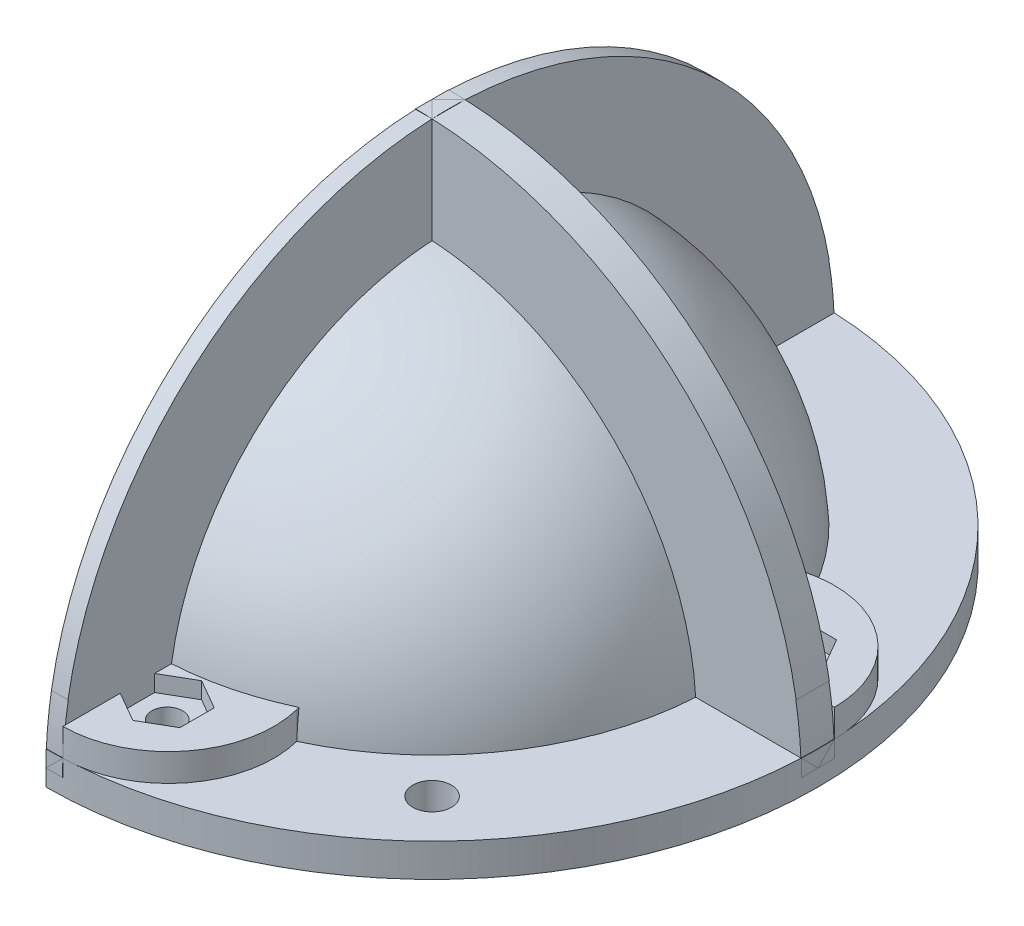
from build123d import *

# Parameters (mm, degrees)
BOSS_EXTRUDE1_DEPTH      = 1.5
BOSS_EXTRUDE1_DEPTH_BACK = 1.5
BOSS_EXTRUDE2_DEPTH      = 1.5
BOSS_EXTRUDE2_DEPTH_BACK = 1.5
SKETCH6_W                = 9.75
SKETCH6_H                = 3
SKETCH6_W_2              = 0.965
SKETCH6_H_2              = 1.5
BOSS_EXTRUDE4_DEPTH      = 2.5
CUT_EXTRUDE1_DEPTH       = 1.5
SKETCH11_R               = 1.4
CUT_EXTRUDE2_DEPTH       = 60.213596412
SKETCH13_R               = 10.5
BOSS_EXTRUDE5_DEPTH      = 2
BOSS_EXTRUDE5_DEPTH_BACK = 5
CUT_EXTRUDE3_DEPTH       = 10
CUT_EXTRUDE3_DEPTH_BACK  = 10
SKETCH15_R               = 9
CUT_EXTRUDE4_DEPTH       = 10
CUT_EXTRUDE5_DEPTH       = 4.1
SKETCH19_R               = 8.75
CUT_EXTRUDE6_DEPTH       = 2.5
SKETCH23_R               = 1.75
CUT_EXTRUDE9_DEPTH       = 10


with BuildPart() as part:
    # Sketch1 → Revolve1 (revolve)
    with BuildSketch(Plane.XY, mode=Mode.PRIVATE) as revolve1_sk:
        with BuildLine():
            Line((-20.885, 0), (-20.885, 11.793939121))
            ThreePointArc((-20.885, 11.793939121), (-12.091372858, 20.714220415), (0, 23.985))
            Line((0, 23.985), (0, 25.485))
            ThreePointArc((0, 25.485), (-18.020616319, 18.020616319), (-25.485, 0))
            Line((-25.485, 0), (-24.285, 0))
            Line((-24.285, 0), (-24.285, 0.5))
            Line((-24.285, 0.5), (-22.085, 0.5))
            Line((-22.085, 0.5), (-22.085, 0))
            Line((-22.085, 0), (-20.885, 0))
        make_face()
    revolve(revolve1_sk.sketch.rotate(Axis((0, 0, 0), (0, 1, 0)), 270), axis=Axis((0, 0, 0), (0, 1, 0)))



with BuildPart() as body_2:
    # Sketch2 → Boss-Extrude1 (new, two sides)
    with BuildSketch(Plane.XY) as boss_extrude1_sk:
        with BuildLine():
            Line((-24.9, 0), (-35, 0))
            ThreePointArc((-35, 0), (0, 35), (35, 0))
            Line((35, 0), (24.9, 0))
            ThreePointArc((24.9, 0), (0, 24.9), (-24.9, 0))
        make_face()
    extrude(amount=BOSS_EXTRUDE1_DEPTH)
    extrude(boss_extrude1_sk.sketch, amount=-BOSS_EXTRUDE1_DEPTH_BACK)

    # Sketch3 → Boss-Extrude2 (add, two sides)
    with BuildSketch(Plane(origin=(0, 0, 0), x_dir=(0, 0, -1), z_dir=(1, 0, 0))) as boss_extrude2_sk:
        with BuildLine():
            Line((35, 0), (24.9, 0))
            ThreePointArc((24.9, 0), (0, 24.9), (-24.9, 0))
            Line((-24.9, 0), (-35, 0))
            ThreePointArc((-35, 0), (0, 35), (35, 0))
        make_face()
    extrude(amount=BOSS_EXTRUDE2_DEPTH)
    extrude(boss_extrude2_sk.sketch, amount=-BOSS_EXTRUDE2_DEPTH_BACK)


with BuildPart() as part_1:
    add(part.part)

    add(body_2.part)  # Revolve3 merges body 2
    # Sketch6 → Revolve3 (revolve)
    with BuildSketch(Plane(origin=(0, 0, 0), x_dir=(0, 0, -1), z_dir=(1, 0, 0)), mode=Mode.PRIVATE) as revolve3_sk:
        with Locations((30.125, 0)):
            Rectangle(SKETCH6_W, SKETCH6_H)
        with Locations((24.7675, 0.75)):
            Rectangle(SKETCH6_W_2, SKETCH6_H_2)
    revolve(revolve3_sk.sketch.rotate(Axis((0, 0, 0), (0, -1, 0)), 180), axis=Axis((0, 0, 0), (0, -1, 0)))

    # Sketch9 → Cut-Revolve1 (revolve, cut)
    with BuildSketch(Plane.XY, mode=Mode.PRIVATE) as cut_revolve1_sk:
        with BuildLine():
            Line((34.507469645, 5.851028856), (35.470882951, 5.851028856))
            Line((35.470882951, 5.851028856), (35.470882951, 1.5))
            Line((35.470882951, 1.5), (34.96784237, 1.5))
            ThreePointArc((34.96784237, 1.5), (34.805712289, 3.682715312), (34.507469645, 5.851028856))
        make_face()
    revolve(cut_revolve1_sk.sketch.rotate(Axis((0, 0, 0), (0, 1, 0)), 180), axis=Axis((0, 0, 0), (0, 1, 0)), mode=Mode.SUBTRACT)

    # Sketch7 → Boss-Extrude4 (add)
    with BuildSketch(Plane(origin=(0, 1.5, 0), x_dir=(1, 0, 0), z_dir=(0, 1, 0))):
        with BuildLine():
            Line((23.044996888, 10.777909974), (22.609782845, 10.667601403))
            ThreePointArc((22.609782845, 10.667601403), (24.220082694, 6.195772291), (24.954959427, 1.5))
            Line((24.954959427, 1.5), (25.396559314, 1.5))
            Line((25.396559314, 1.5), (34.96784237, 1.5))
            ThreePointArc((34.96784237, 1.5), (31.274568745, 9.053705347), (23.044996888, 10.777909974))
        make_face()
        with BuildLine():
            ThreePointArc((10.667601403, -22.609782845), (6.195772291, -24.220082694), (1.5, -24.954959427))
            Line((1.5, -24.954959427), (1.5, -25.396559314))
            Line((1.5, -25.396559314), (1.5, -34.96784237))
            ThreePointArc((1.5, -34.96784237), (9.053705347, -31.274568745), (10.777909974, -23.044996888))
            Line((10.777909974, -23.044996888), (10.667601403, -22.609782845))
        make_face()
        with BuildLine():
            Line((-25.396559314, -1.5), (-34.96784237, -1.5))
            ThreePointArc((-34.96784237, -1.5), (-31.274568745, -9.053705347), (-23.044996888, -10.777909974))
            Line((-23.044996888, -10.777909974), (-22.609782845, -10.667601403))
            ThreePointArc((-22.609782845, -10.667601403), (-24.220082694, -6.195772291), (-24.954959427, -1.5))
            Line((-24.954959427, -1.5), (-25.396559314, -1.5))
        make_face()
        with BuildLine():
            ThreePointArc((-2.626689255, 34.901296588), (-9.387133949, 30.818973666), (-10.777909974, 23.044996888))
            ThreePointArc((-10.777909974, 23.044996888), (-6.25053836, 24.661021779), (-1.5, 25.396559314))
            Line((-1.5, 25.396559314), (-1.5, 34.96784237))
            ThreePointArc((-1.5, 34.96784237), (-2.063612885, 34.939111349), (-2.626689255, 34.901296588))
        make_face()
        with BuildLine():
            Line((-10.777909974, 23.044996888), (-10.667601403, 22.609782845))
            ThreePointArc((-10.667601403, 22.609782845), (-6.195772291, 24.220082694), (-1.5, 24.954959427))
            Line((-1.5, 24.954959427), (-1.5, 25.396559314))
            ThreePointArc((-1.5, 25.396559314), (-6.25053836, 24.661021779), (-10.777909974, 23.044996888))
        make_face()
    extrude(amount=BOSS_EXTRUDE4_DEPTH)

    # Sketch10 → Cut-Extrude1 (cut)
    with BuildSketch(Plane(origin=(0, 4, 0), x_dir=(1, 0, 0), z_dir=(0, 1, 0))):
        Polygon((4.2, -31.327119097), (6.9, -29.76827337), (6.9, -26.650581916), (4.2, -25.091736189), (1.5, -26.650581916), (1.5, -29.76827337), align=None)
        Polygon((-25.091736189, -4.2), (-26.650581916, -1.5), (-29.76827337, -1.5), (-31.327119097, -4.2), (-29.76827337, -6.9), (-26.650581916, -6.9), align=None)
        Polygon((-4.2, 31.327119097), (-6.9, 29.76827337), (-6.9, 26.650581916), (-4.2, 25.091736189), (-1.5, 26.650581916), (-1.5, 29.76827337), align=None)
        Polygon((31.327119097, 4.2), (29.76827337, 6.9), (26.650581916, 6.9), (25.091736189, 4.2), (26.650581916, 1.5), (29.76827337, 1.5), align=None)
    extrude(amount=-CUT_EXTRUDE1_DEPTH, mode=Mode.SUBTRACT)

    # Sketch11 → Cut-Extrude2 (cut, through all)
    with BuildSketch(Plane(origin=(0, 2.5, 0), x_dir=(1, 0, 0), z_dir=(0, 1, 0))):
        with Locations(Location((28.209427643, 4.2, 0), (0, 0, 270))):
            Circle(SKETCH11_R)
        with Locations(Location((4.2, -28.209427643, 0), (0, 0, 270))):
            Circle(SKETCH11_R)
        with Locations(Location((-28.209427643, -4.2, 0), (0, 0, 270))):
            Circle(SKETCH11_R)
        with Locations(Location((-4.2, 28.209427643, 0), (0, 0, 270))):
            Circle(SKETCH11_R)
    extrude(amount=-CUT_EXTRUDE2_DEPTH, mode=Mode.SUBTRACT)

    # Sketch13 → Boss-Extrude5 (add, two sides)
    with BuildSketch(Plane(origin=(-12.655947457, 12.655947457, 12.655947457), x_dir=(-0.8164965809277261, -0.408248290463863, -0.408248290463863), z_dir=(0.5773502691896257, -0.5773502691896258, -0.5773502691896258))) as boss_extrude5_sk:
        with Locations(Location((0, 0, 0), (0, 0, 270))):
            Circle(SKETCH13_R)
    extrude(amount=BOSS_EXTRUDE5_DEPTH)
    extrude(boss_extrude5_sk.sketch, amount=-BOSS_EXTRUDE5_DEPTH_BACK)

    # Sketch12 → Cut-Extrude3 (cut, two sides)
    with BuildSketch(Plane(origin=(-12.655947457, 12.655947457, 12.655947457), x_dir=(-0.8164965809277261, -0.408248290463863, -0.408248290463863), z_dir=(0.5773502691896257, -0.5773502691896258, -0.5773502691896258))) as cut_extrude3_sk:
        with BuildLine():
            Line((0.352106197, -6.089829327), (5.097893803, -3.349847575))
            ThreePointArc((5.097893803, -3.349847575), (5.282754963, 3.05), (-0.352106197, 6.089829327))
            Line((-0.352106197, 6.089829327), (-5.097893803, 3.349847575))
            ThreePointArc((-5.097893803, 3.349847575), (-5.282754963, -3.05), (0.352106197, -6.089829327))
        make_face()
    extrude(amount=CUT_EXTRUDE3_DEPTH, mode=Mode.SUBTRACT)
    extrude(cut_extrude3_sk.sketch, amount=-CUT_EXTRUDE3_DEPTH_BACK, mode=Mode.SUBTRACT)

    # Sketch15 → Cut-Extrude4 (cut)
    with BuildSketch(Plane(origin=(-11.501246918, 11.501246918, 11.501246918), x_dir=(-0.40824829046386274, 0.40824829046386296, -0.8164965809277264), z_dir=(0.5773502691896258, -0.5773502691896262, -0.5773502691896255))):
        Circle(SKETCH15_R)
    extrude(amount=CUT_EXTRUDE4_DEPTH, mode=Mode.SUBTRACT)

    # Sketch18 → Cut-Extrude5 (cut)
    with BuildSketch(Plane(origin=(-15.542698803, 15.542698803, 15.542698803), x_dir=(0.40824829046386274, -0.40824829046386296, 0.8164965809277264), z_dir=(-0.5773502691896258, 0.5773502691896262, 0.5773502691896255))):
        with BuildLine():
            Line((0.654858953, -7.06973548), (5.795141047, -4.101992229))
            ThreePointArc((5.795141047, -4.101992229), (6.148780367, 3.55), (-0.654858953, 7.06973548))
            ThreePointArc((-0.654858953, 7.06973548), (-3.55, 6.148780367), (-5.795141047, 4.101992229))
            ThreePointArc((-5.795141047, 4.101992229), (-6.148780367, -3.55), (0.654858953, -7.06973548))
        make_face()
    extrude(amount=-CUT_EXTRUDE5_DEPTH, mode=Mode.SUBTRACT)

    # Sketch19 → Cut-Extrude6 (cut)
    with BuildSketch(Plane(origin=(-15.542698803, 15.542698803, 15.542698803), x_dir=(0.40824829046386274, -0.40824829046386296, 0.8164965809277264), z_dir=(-0.5773502691896258, 0.5773502691896262, 0.5773502691896255))):
        with Locations(Location((0, 0, 0), (0, 0, 270))):
            Circle(SKETCH19_R)
    extrude(amount=-CUT_EXTRUDE6_DEPTH, mode=Mode.SUBTRACT)

    # Sketch23 → Cut-Extrude9 (cut)
    with BuildSketch(Plane(origin=(0, 1.5, 0), x_dir=(1, 0, 0), z_dir=(0, 1, 0))):
        with Locations(Location((21.213203436, -21.213203436, 0), (0, 0, 270))):
            Circle(SKETCH23_R)
        with Locations(Location((-21.213203436, 21.213203436, 0), (0, 0, 270))):
            Circle(SKETCH23_R)
    extrude(amount=-CUT_EXTRUDE9_DEPTH, mode=Mode.SUBTRACT)

    # SurfaceCut1
    split(bisect_by=Plane(origin=(0, 0, 0), x_dir=(0, 0, -1), z_dir=(1, 0, 0)), keep=Keep.TOP)


solid = part_1.part
